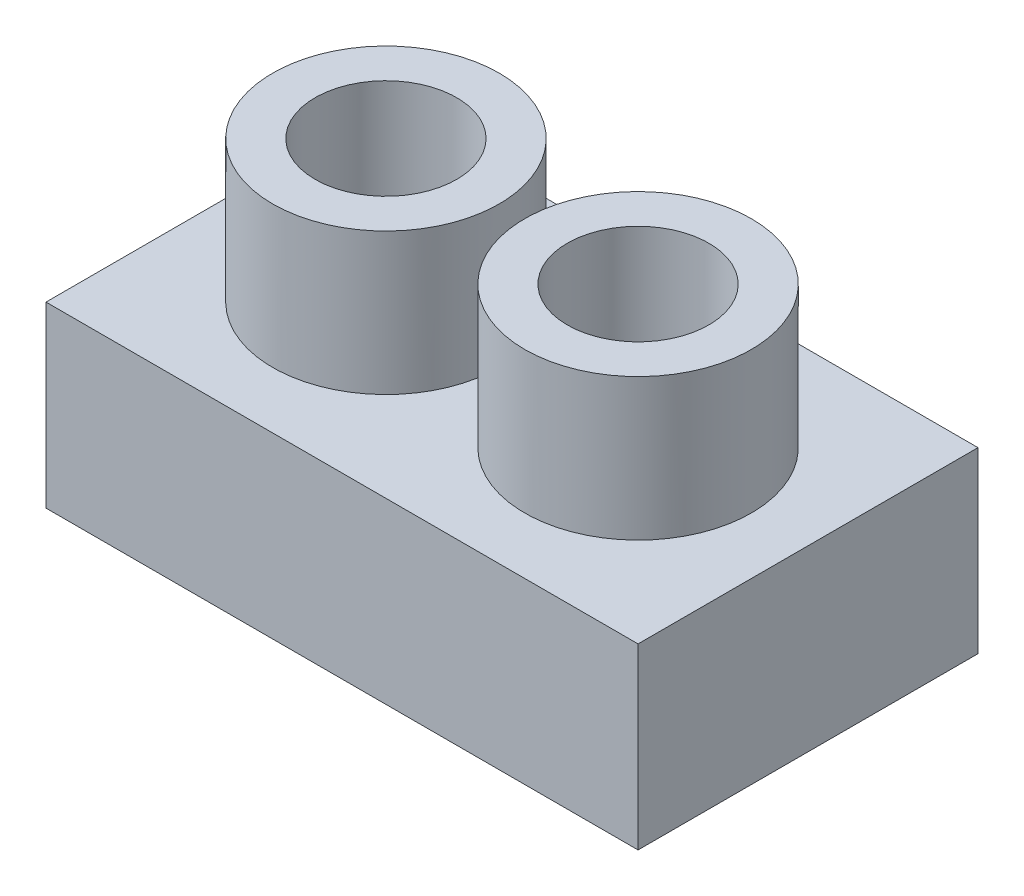
from build123d import *

# Parameters (mm, degrees)
SKETCH1_W           = 20.9
SKETCH1_H           = 12
BOSS_EXTRUDE1_DEPTH = 6.3
SKETCH2_R           = 4
BOSS_EXTRUDE2_DEPTH = 5
SKETCH3_R           = 2.5
CUT_EXTRUDE1_DEPTH  = 11.3


with BuildPart() as part:
    # Sketch1 → Boss-Extrude1 (new body)
    with BuildSketch(Plane(origin=(0, 0, 0), x_dir=(1, 0, 0), z_dir=(0, 1, 0))):
        Rectangle(SKETCH1_W, SKETCH1_H)
    extrude(amount=BOSS_EXTRUDE1_DEPTH)

    # Sketch2 → Boss-Extrude2 (add)
    with BuildSketch(Plane(origin=(0, 6.3, 0), x_dir=(1, 0, 0), z_dir=(0, 1, 0))):
        with Locations((-4.45, 0)):
            Circle(SKETCH2_R)
        with Locations((4.45, 0)):
            Circle(SKETCH2_R)
    extrude(amount=BOSS_EXTRUDE2_DEPTH)

    # Sketch3 → Cut-Extrude1 (cut)
    with BuildSketch(Plane(origin=(0, 11.3, 0), x_dir=(1, 0, 0), z_dir=(0, 1, 0))):
        with Locations((4.45, 0)):
            Circle(SKETCH3_R)
        with Locations((-4.45, 0)):
            Circle(SKETCH3_R)
    extrude(amount=-CUT_EXTRUDE1_DEPTH, mode=Mode.SUBTRACT)


solid = part.part
